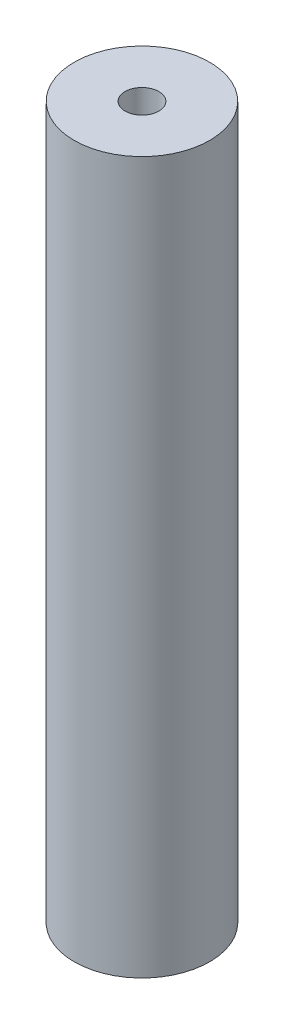
from build123d import *

# Parameters (mm, degrees)
SKETCH1_R           = 10
BOSS_EXTRUDE1_DEPTH = 105
SKETCH2_R           = 2.5
CUT_EXTRUDE1_DEPTH  = 8
SKETCH3_R           = 2.5
CUT_EXTRUDE2_DEPTH  = 8


with BuildPart() as part:
    # Sketch1 → Boss-Extrude1 (new body)
    with BuildSketch(Plane(origin=(0, 0, 0), x_dir=(1, 0, 0), z_dir=(0, 1, 0))):
        Circle(SKETCH1_R)
    extrude(amount=BOSS_EXTRUDE1_DEPTH)

    # Sketch2 → Cut-Extrude1 (cut)
    with BuildSketch(Plane(origin=(0, 105, 0), x_dir=(1, 0, 0), z_dir=(0, 1, 0))):
        Circle(SKETCH2_R)
    extrude(amount=-CUT_EXTRUDE1_DEPTH, mode=Mode.SUBTRACT)

    # Sketch3 → Cut-Extrude2 (cut)
    with BuildSketch(Plane(origin=(0, 0, 0), x_dir=(-1, 0, 0), z_dir=(0, -1, 0))):
        Circle(SKETCH3_R)
    extrude(amount=-CUT_EXTRUDE2_DEPTH, mode=Mode.SUBTRACT)


solid = part.part
